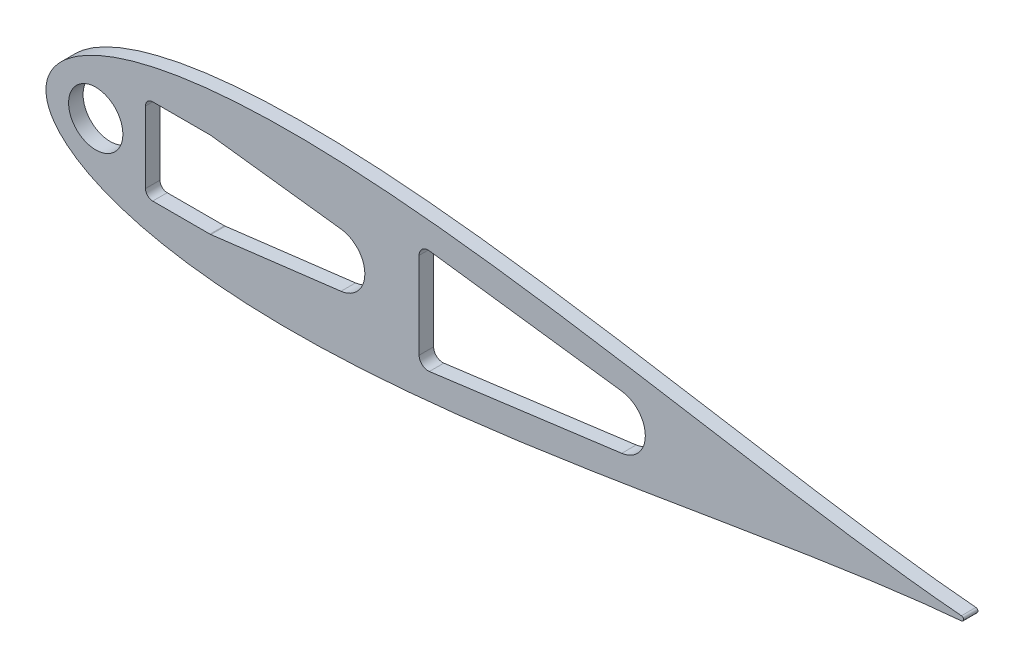
from build123d import *

# Parameters (mm, degrees)
BOSS_EXTRUDE1_DEPTH = 5.4737
SCALE1_SCALE        = 0.5
BOSS_EXTRUDE2_DEPTH = 5.08
SKETCH10_W          = 25.167167629
SKETCH10_H          = 30.1625
CUT_EXTRUDE6_DEPTH  = 6.0800001
FILLET1_R           = 2.54
CUT_EXTRUDE8_DEPTH  = 6.0800001
CUT_EXTRUDE9_DEPTH  = 6.0800001
SKETCH19_R          = 9.525
CUT_EXTRUDE10_DEPTH = 6.0800001


with BuildPart() as part:
    # Sketch2 → Boss-Extrude1 (new body)
    with BuildSketch(Plane.XY):
        with BuildLine():
            add(Edge.make_bspline(
                [(642.510849283, 1.582039112), (641.993392355, 1.625070631), (638.093728429, 1.953546407), (630.413817462, 2.663385493), (619.014124193, 3.849253664), (606.374988512, 5.304428983), (592.543922516, 7.037634907), (577.585454095, 9.050636147), (561.564270734, 11.338919625), (544.549749946, 13.890665375), (526.614143658, 16.687720753), (507.832591566, 19.705111663), (488.282710288, 22.911672601), (468.044367735, 26.27043606), (447.199424328, 29.739007432), (425.831595832, 33.270324121), (404.02631566, 36.813220545), (381.870662856, 40.313266856), (359.453314895, 43.713502532), (336.86454415, 46.955447457), (314.196207315, 49.979843895), (291.541767704, 52.727712704), (268.996310773, 55.141201012), (246.65655865, 57.164603829), (224.620860897, 58.745176641), (202.989192599, 59.8341217), (181.863132616, 60.387506142), (161.345829027, 60.366961324), (141.542033828, 59.739895824), (122.558104573, 58.481758104), (104.502313427, 56.574303932), (87.485018636, 54.008935199), (71.619696083, 50.784752003), (57.023709725, 46.912543066), (43.82045433, 42.41500246), (32.141645239, 37.332204029), (22.129107375, 31.731455339), (13.932423524, 25.726412106), (7.689616489, 19.513207632), (3.463136343, 13.420354421), (1.106333228, 7.923389435), (0.154611582, 3.513796615), (-0.062151598, 0), (0.154611582, -3.513796615), (1.106333228, -7.923389435), (3.463136343, -13.420354421), (7.689616489, -19.513207632), (13.932423524, -25.726412106), (22.129107375, -31.731455339), (32.141645239, -37.332204029), (43.82045433, -42.41500246), (57.023709725, -46.912543066), (71.619696083, -50.784752003), (87.485018636, -54.008935199), (104.502313427, -56.574303932), (122.558104573, -58.481758104), (141.542033828, -59.739895824), (161.345829027, -60.366961324), (181.863132616, -60.387506142), (202.989192599, -59.8341217), (224.620860897, -58.745176641), (246.65655865, -57.164603829), (268.996310773, -55.141201012), (291.541767704, -52.727712704), (314.196207315, -49.979843895), (336.86454415, -46.955447457), (359.453314895, -43.713502532), (381.870662856, -40.313266856), (404.02631566, -36.813220545), (425.831595832, -33.270324121), (447.199424328, -29.739007432), (468.044367735, -26.27043606), (488.282710288, -22.911672601), (507.832591566, -19.705111663), (526.614143658, -16.687720753), (544.549749946, -13.890665375), (561.564270734, -11.338919625), (577.585454095, -9.050636147), (592.543922516, -7.037634907), (606.374988512, -5.304428983), (619.014124193, -3.849253664), (630.413817462, -2.663385493), (638.093728429, -1.953546407), (641.993392355, -1.625070631), (642.510849283, -1.582039112)],
                knots=[0.020157042, 0.020157042, 0.020157042, 0.020157042, 0.021270888, 0.028552555, 0.036780684, 0.045920102, 0.055931764, 0.066772884, 0.07839713, 0.090754827, 0.103793165, 0.117456432, 0.131686226, 0.146421738, 0.161599998, 0.177156133, 0.193023668, 0.209134786, 0.225420633, 0.241811602, 0.258237647, 0.274628557, 0.290914287, 0.307025229, 0.322892517, 0.338448342, 0.353626207, 0.368361232, 0.382590428, 0.396252961, 0.409290412, 0.42164701, 0.433269881, 0.444109249, 0.45411864, 0.463255055, 0.471479114, 0.478755289, 0.485052318, 0.490344026, 0.494609833, 0.497833231, 0.5, 0.502166769, 0.505390167, 0.509655974, 0.514947682, 0.521244711, 0.528520886, 0.536744945, 0.54588136, 0.555890751, 0.566730119, 0.57835299, 0.590709588, 0.603747039, 0.617409572, 0.631638768, 0.646373793, 0.661551658, 0.677107483, 0.692974771, 0.709085713, 0.725371443, 0.741762353, 0.758188398, 0.774579367, 0.790865214, 0.806976332, 0.822843867, 0.838400002, 0.853578262, 0.868313774, 0.882543568, 0.896206835, 0.909245173, 0.92160287, 0.933227116, 0.944068236, 0.954079898, 0.963219316, 0.971447445, 0.978729112, 0.979842958, 0.979842958, 0.979842958, 0.979842958], degree=3))
            ThreePointArc((642.510849283, -1.582039112), (643.966787522, 0), (642.510849283, 1.582039112))
        make_face()
    extrude(amount=BOSS_EXTRUDE1_DEPTH)


with BuildPart() as part_1:
    # Scale1: scaled about (0, 0, 0)
    add(part.part.scale(SCALE1_SCALE))

    # Sketch11 → Boss-Extrude2 (add)
    with BuildSketch(Plane(origin=(0, 0, 0), x_dir=(-1, 0, 0), z_dir=(0, 0, -1))):
        with BuildLine():
            ThreePointArc((-321.255424642, 0.791019556), (-321.983393761, 0), (-321.255424642, -0.791019556))
            add(Edge.make_bspline(
                [(-321.255424642, -0.791019556), (-320.996696177, -0.812535315), (-319.046864214, -0.976773204), (-315.206908731, -1.331692747), (-309.507062097, -1.924626832), (-303.187494256, -2.652214492), (-296.271961258, -3.518817454), (-288.792727048, -4.525318074), (-280.782135367, -5.669459812), (-272.274874973, -6.945332687), (-263.307071829, -8.343860376), (-253.916295783, -9.852555831), (-244.141355144, -11.4558363), (-234.022183867, -13.13521803), (-223.599712164, -14.869503716), (-212.915797916, -16.63516206), (-202.01315783, -18.406610273), (-190.935331428, -20.156633428), (-179.726657448, -21.856751266), (-168.432272075, -23.477723728), (-157.098103658, -24.989921948), (-145.770883852, -26.363856352), (-134.498155387, -27.570600506), (-123.328279325, -28.582301914), (-112.310430449, -29.372588321), (-101.4945963, -29.91706085), (-90.931566308, -30.193753071), (-80.672914513, -30.183480662), (-70.771016914, -29.869947912), (-61.279052286, -29.240879052), (-52.251156714, -28.287151966), (-43.742509318, -27.0044676), (-35.809848042, -25.392376001), (-28.511854862, -23.456271533), (-21.910227165, -21.20750123), (-16.070822619, -18.666102014), (-11.064553688, -15.865727669), (-6.966211762, -12.863206053), (-3.844808245, -9.756603816), (-1.731568172, -6.71017721), (-0.553166614, -3.961694717), (-0.077305791, -1.756898308), (0.031075799, 0), (-0.077305791, 1.756898308), (-0.553166614, 3.961694717), (-1.731568172, 6.71017721), (-3.844808245, 9.756603816), (-6.966211762, 12.863206053), (-11.064553688, 15.865727669), (-16.070822619, 18.666102014), (-21.910227165, 21.20750123), (-28.511854862, 23.456271533), (-35.809848042, 25.392376001), (-43.742509318, 27.0044676), (-52.251156714, 28.287151966), (-61.279052286, 29.240879052), (-70.771016914, 29.869947912), (-80.672914513, 30.183480662), (-90.931566308, 30.193753071), (-101.4945963, 29.91706085), (-112.310430449, 29.372588321), (-123.328279325, 28.582301914), (-134.498155387, 27.570600506), (-145.770883852, 26.363856352), (-157.098103658, 24.989921948), (-168.432272075, 23.477723728), (-179.726657448, 21.856751266), (-190.935331428, 20.156633428), (-202.01315783, 18.406610273), (-212.915797916, 16.63516206), (-223.599712164, 14.869503716), (-234.022183867, 13.13521803), (-244.141355144, 11.4558363), (-253.916295783, 9.852555831), (-263.307071829, 8.343860376), (-272.274874973, 6.945332687), (-280.782135367, 5.669459812), (-288.792727048, 4.525318074), (-296.271961258, 3.518817454), (-303.187494256, 2.652214492), (-309.507062097, 1.924626832), (-315.206908731, 1.331692747), (-319.046864214, 0.976773204), (-320.996696177, 0.812535315), (-321.255424642, 0.791019556)],
                knots=[0.020157042, 0.020157042, 0.020157042, 0.020157042, 0.021270888, 0.028552555, 0.036780684, 0.045920102, 0.055931764, 0.066772884, 0.07839713, 0.090754827, 0.103793165, 0.117456432, 0.131686226, 0.146421738, 0.161599998, 0.177156133, 0.193023668, 0.209134786, 0.225420633, 0.241811602, 0.258237647, 0.274628557, 0.290914287, 0.307025229, 0.322892517, 0.338448342, 0.353626207, 0.368361232, 0.382590428, 0.396252961, 0.409290412, 0.42164701, 0.433269881, 0.444109249, 0.45411864, 0.463255055, 0.471479114, 0.478755289, 0.485052318, 0.490344026, 0.494609833, 0.497833231, 0.5, 0.502166769, 0.505390167, 0.509655974, 0.514947682, 0.521244711, 0.528520886, 0.536744945, 0.54588136, 0.555890751, 0.566730119, 0.57835299, 0.590709588, 0.603747039, 0.617409572, 0.631638768, 0.646373793, 0.661551658, 0.677107483, 0.692974771, 0.709085713, 0.725371443, 0.741762353, 0.758188398, 0.774579367, 0.790865214, 0.806976332, 0.822843867, 0.838400002, 0.853578262, 0.868313774, 0.882543568, 0.896206835, 0.909245173, 0.92160287, 0.933227116, 0.944068236, 0.954079898, 0.963219316, 0.971447445, 0.978729112, 0.979842958, 0.979842958, 0.979842958, 0.979842958], degree=3))
        make_face()
    extrude(amount=-BOSS_EXTRUDE2_DEPTH)

    # Sketch10 → Cut-Extrude6 (cut, through all)
    with BuildSketch(Plane.XY):
        with Locations((47.508583814, 0)):
            Rectangle(SKETCH10_W, SKETCH10_H)
    extrude(amount=CUT_EXTRUDE6_DEPTH, mode=Mode.SUBTRACT)

    # Fillet1
    fillet1_edges = [part_1.edges().sort_by_distance(p)[0] for p in [
        (60.092167629, -15.08125, 2.54),
        (60.092167629, 15.08125, 2.54),
        (34.925, 15.08125, 2.54),
        (34.925, -15.08125, 2.54),
    ]]
    fillet(fillet1_edges, radius=FILLET1_R)

    # Sketch16 → Cut-Extrude8 (cut, through all)
    with BuildSketch(Plane.XY.offset(5.08)):
        with BuildLine():
            Line((102.372583815, -9.525), (100.594583815, -9.525))
            ThreePointArc((100.594583815, -9.525), (91.069583815, 0), (100.594583815, 9.525))
            Line((100.594583815, 9.525), (102.372583815, 9.525))
            ThreePointArc((102.372583815, 9.525), (111.897583815, 0), (102.372583815, -9.525))
        make_face()
    extrude(amount=-CUT_EXTRUDE8_DEPTH, mode=Mode.SUBTRACT)

    # Sketch18 → Cut-Extrude9 (cut, through all)
    with BuildSketch(Plane.XY.offset(5.08)):
        with BuildLine():
            Line((57.861745058, 15.062313628), (103.533499174, 9.453988604))
            ThreePointArc((103.533499174, 9.453988604), (111.897583815, 0), (103.533499174, -9.453988604))
            Line((103.533499174, -9.453988604), (57.861745058, -15.062313628))
            ThreePointArc((57.861745058, -15.062313628), (59.454524939, -14.224293869), (60.092167629, -12.54125))
            Line((60.092167629, -12.54125), (60.092167629, 12.54125))
            ThreePointArc((60.092167629, 12.54125), (59.454524939, 14.224293869), (57.861745058, 15.062313628))
        make_face()
    extrude(amount=-CUT_EXTRUDE9_DEPTH, mode=Mode.SUBTRACT)

    # Sketch19 → Cut-Extrude10 (cut, through all)
    with BuildSketch(Plane.XY.offset(5.08)):
        with Locations((17.4625, 0)):
            Circle(SKETCH19_R)
        with BuildLine():
            Line((130.947583815, 15.182724176), (130.947583815, -15.182724176))
            ThreePointArc((130.947583815, -15.182724176), (132.029160852, -17.569815565), (134.537004475, -18.330561611))
            Line((134.537004475, -18.330561611), (202.040845795, -9.443512305))
            ThreePointArc((202.040845795, -9.443512305), (210.322583815, 0), (202.040845795, 9.443512305))
            Line((202.040845795, 9.443512305), (134.537004475, 18.330561611))
            ThreePointArc((134.537004475, 18.330561611), (132.029160852, 17.569815565), (130.947583815, 15.182724176))
        make_face()
    extrude(amount=-CUT_EXTRUDE10_DEPTH, mode=Mode.SUBTRACT)


solid = part_1.part
